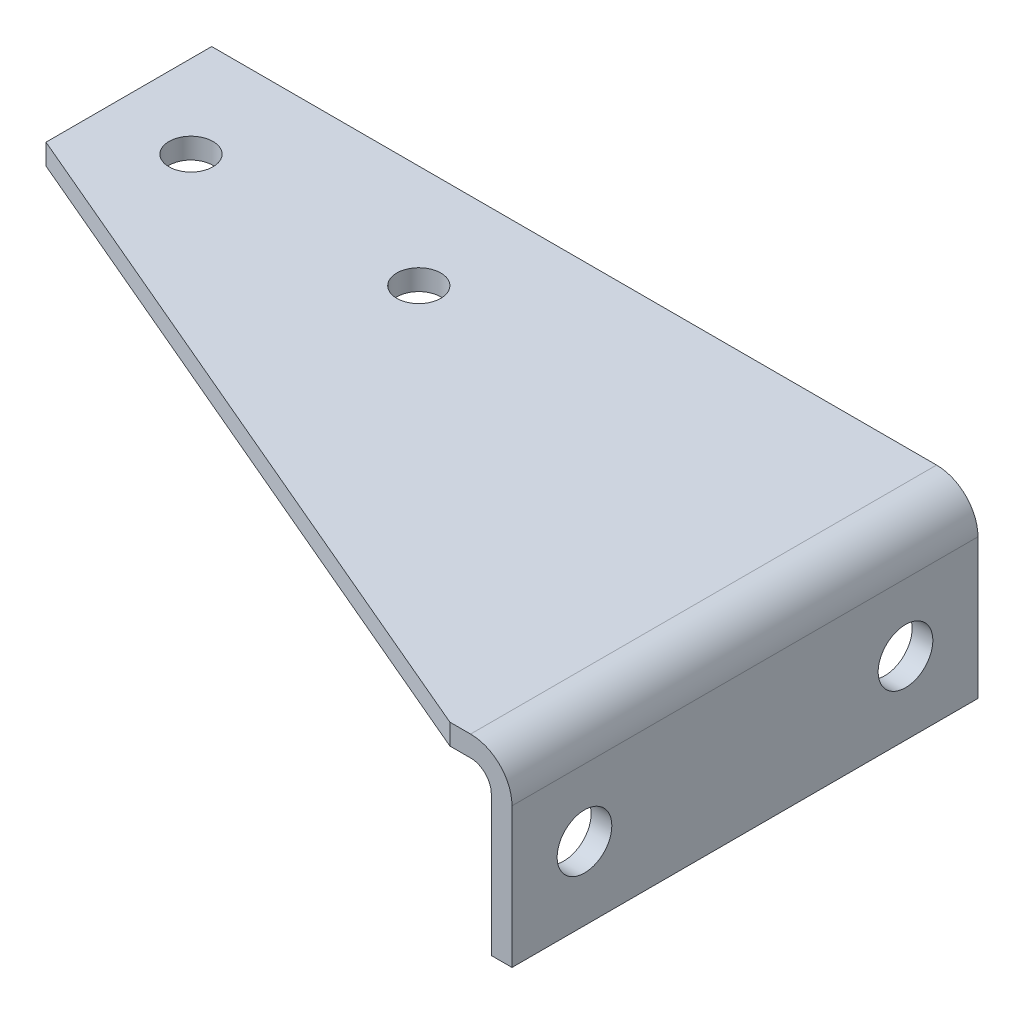
from build123d import *

# Parameters (mm, degrees)
BASE_EXTRUDE_THIN_DEPTH = 142.875
CUT_CNR_DEPTH           = 7.35
CUT_CNR_DEPTH_BACK      = 50.276
HOLE_FLG_D              = 16.764
HOLE_TOP_D              = 13.49375
HOLE_TOP_DEPTH          = 25.4


with BuildPart() as part:
    # Sketch1 → Base-Extrude-Thin (new body)
    with BuildSketch(Plane.XY):
        with BuildLine():
            Line((-228.6, 0), (-6.35, 0))
            ThreePointArc((-6.35, 0), (-1.859871939, -1.859871939), (0, -6.35))
            Line((0, -6.35), (0, -49.276))
            Line((0, -49.276), (6.35, -49.276))
            Line((6.35, -49.276), (6.35, -6.35))
            ThreePointArc((6.35, -6.35), (2.630256121, 2.630256121), (-6.35, 6.35))
            Line((-6.35, 6.35), (-228.6, 6.35))
            Line((-228.6, 6.35), (-228.6, 0))
        make_face()
    extrude(amount=BASE_EXTRUDE_THIN_DEPTH)

    # Sketch2 → Cut cnr (cut, two sides)
    with BuildSketch(Plane(origin=(0, 0, 0), x_dir=(1, 0, 0), z_dir=(0, 1, 0))) as cut_cnr_sk:
        Polygon((-714.082135383, 156.243851855), (-228.6, -50.8), (-12.7, -142.875), (472.782135383, -349.918851855), (58.694431674, -1320.883122621), (-1128.169839092, -814.720418912), align=None)
    extrude(amount=CUT_CNR_DEPTH, mode=Mode.SUBTRACT)
    extrude(cut_cnr_sk.sketch, amount=-CUT_CNR_DEPTH_BACK, mode=Mode.SUBTRACT)

    # Hole-flg (through all)
    with Locations(Plane(origin=(6.35, 0, 0), x_dir=(0, 0, -1), z_dir=(1, 0, 0))):
        with Locations((-120.65, -26.924), (-22.225, -26.924)):
            Hole(HOLE_FLG_D / 2)

    # Hole-top
    with Locations(Plane(origin=(0, 6.35, 0), x_dir=(-1, 0, 0), z_dir=(0, 1, 0))):
        with Locations((203.2, 31.75), (133.35, 31.75)):
            Hole(HOLE_TOP_D / 2, depth=HOLE_TOP_DEPTH)


solid = part.part
